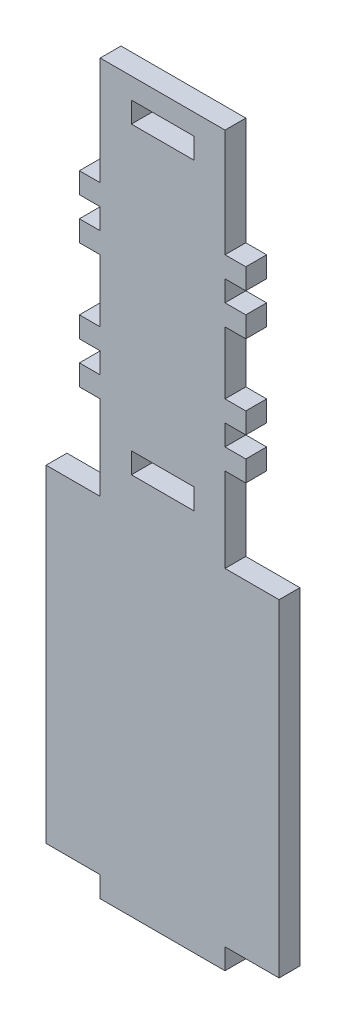
from build123d import *

# Parameters (mm, degrees)
SKETCH1_W           = 19.05
SKETCH1_H           = 6.35
BOSS_EXTRUDE1_DEPTH = 6.35
CUT_EXTRUDE1_DEPTH  = 6.35


with BuildPart() as part:
    # Sketch1 → Boss-Extrude1 (new body)
    with BuildSketch(Plane.XY):
        Polygon((19.05, -3.175), (-19.05, -3.175), (-19.05, 3.175), (-35.56, 3.175), (-35.56, 219.075), (35.56, 219.075), (35.56, 3.175), (19.05, 3.175), align=None)
        with Locations((0, 209.55)):
            Rectangle(SKETCH1_W, SKETCH1_H, mode=Mode.SUBTRACT)
        with Locations((0, 116.84)):
            Rectangle(SKETCH1_W, SKETCH1_H, mode=Mode.SUBTRACT)
    extrude(amount=BOSS_EXTRUDE1_DEPTH)

    # Sketch3 → Cut-Extrude1 (cut)
    with BuildSketch(Plane(origin=(0, 0, 0), x_dir=(-1, 0, 0), z_dir=(0, 0, -1))):
        Polygon((-35.56, 219.075), (-19.05, 219.075), (-19.05, 186.108405272), (-25.4, 186.108405272), (-25.4, 179.758405272), (-19.05, 179.758405272), (-19.05, 173.408405272), (-25.4, 173.408405272), (-25.4, 167.058405272), (-19.05, 167.058405272), (-19.05, 148.008405272), (-25.4, 148.008405272), (-25.4, 141.658405272), (-19.05, 141.658405272), (-19.05, 135.308405272), (-25.4, 135.308405272), (-25.4, 128.958405272), (-19.05, 128.958405272), (-19.05, 103.1875), (-35.56, 103.1875), align=None)
        Polygon((35.56, 103.1875), (19.05, 103.1875), (19.05, 128.958405272), (25.4, 128.958405272), (25.4, 135.308405272), (19.05, 135.308405272), (19.05, 141.658405272), (25.4, 141.658405272), (25.4, 148.008405272), (19.05, 148.008405272), (19.05, 167.058405272), (25.4, 167.058405272), (25.4, 173.408405272), (19.05, 173.408405272), (19.05, 179.758405272), (25.4, 179.758405272), (25.4, 186.108405272), (19.05, 186.108405272), (19.05, 219.075), (35.56, 219.075), align=None)
    extrude(amount=-CUT_EXTRUDE1_DEPTH, mode=Mode.SUBTRACT)


solid = part.part
